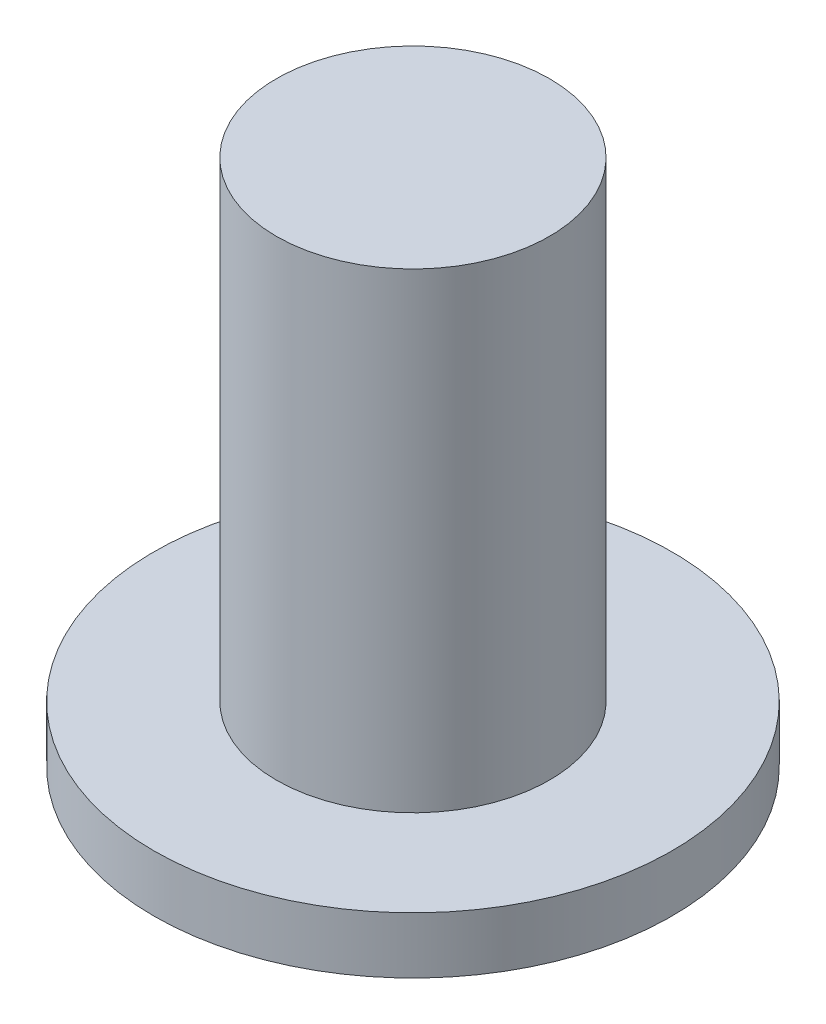
from build123d import *

# Parameters (mm, degrees)
SKETCH_1_R      = 2.75
EXTRUDE_1_DEPTH = 0.6
SKETCH_2_R      = 1.45
EXTRUDE_2_DEPTH = 5


with BuildPart() as part:
    # 草图1 → 凸台-拉伸1 (new body)
    with BuildSketch(Plane(origin=(0, 0, 0), x_dir=(1, 0, 0), z_dir=(0, 1, 0))):
        Circle(SKETCH_1_R)
    extrude(amount=EXTRUDE_1_DEPTH)

    # 草图2 → 凸台-拉伸2 (add)
    with BuildSketch(Plane(origin=(0, 0.6, 0), x_dir=(1, 0, 0), z_dir=(0, 1, 0))):
        Circle(SKETCH_2_R)
    extrude(amount=EXTRUDE_2_DEPTH)


solid = part.part
